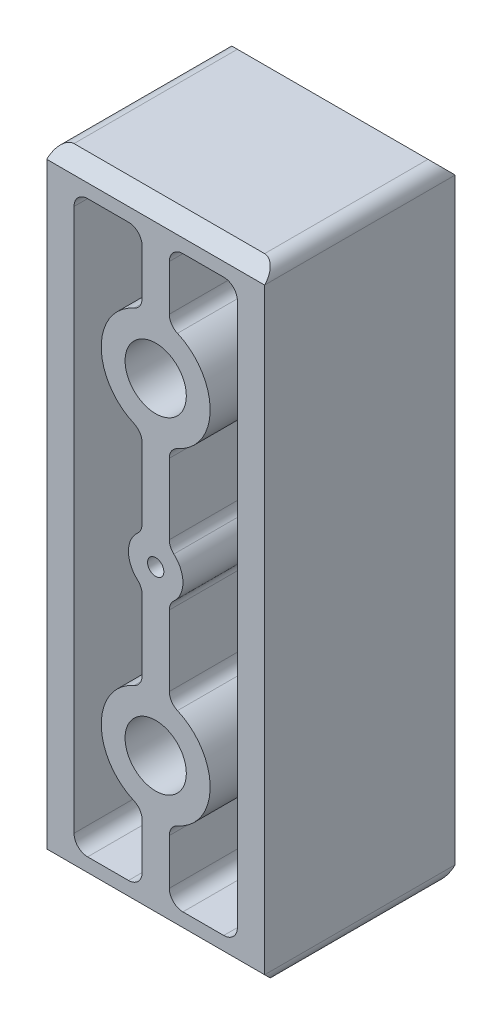
from build123d import *

# Parameters (mm, degrees)
SKETCH1_W                  = 50.8
SKETCH1_H                  = 145.6436
SKETCH1_R                  = 7.14375
BOSS_EXTRUDE1_DEPTH        = 22.225
CUT_EXTRUDE2_DEPTH         = 45.45
FILLET1_R                  = 3.175
CUT_EXTRUDE4_DEPTH         = 51.8
MIRROR3_COPY_1_DEPTH       = 45.45
MIRROR3_COPY_2_DEPTH       = 45.45
MIRROR3_COPY_3_DEPTH       = 51.8
F_10_24_TAPPED_HOLE1_D     = 3.7973
F_10_24_TAPPED_HOLE1_DEPTH = 14.986
F_10_24_TAPPED_HOLE1_TIP   = 1.140824014
FILLET2_R                  = 3.175


with BuildPart() as part:
    # Sketch1 → Boss-Extrude1 (new body, symmetric)
    with BuildSketch(Plane.XY):
        Rectangle(SKETCH1_W, SKETCH1_H)
        with Locations((0, 38.1)):
            Circle(SKETCH1_R, mode=Mode.SUBTRACT)
        with Locations((0, -38.1)):
            Circle(SKETCH1_R, mode=Mode.SUBTRACT)
    extrude(amount=BOSS_EXTRUDE1_DEPTH, both=True)

    # Sketch3 → Cut-Extrude2 (cut, through all)
    with BuildSketch(Plane.XY.offset(22.225)):
        with BuildLine():
            Line((19.05, 66.4718), (19.05, 0))
            Line((19.05, 0), (6.35, 0))
            ThreePointArc((6.35, 0), (5.499261314, 3.175), (3.175, 5.499261314))
            Line((3.175, 5.499261314), (3.175, 25.803277876))
            ThreePointArc((3.175, 25.803277876), (12.7, 38.1), (3.175, 50.396722124))
            Line((3.175, 50.396722124), (3.175, 66.4718))
            Line((3.175, 66.4718), (19.05, 66.4718))
        make_face()
    cut_extrude2 = extrude(amount=-CUT_EXTRUDE2_DEPTH, mode=Mode.SUBTRACT)

    # Mirror4: Cut-Extrude2 across plane
    add(cut_extrude2.mirror(Plane(origin=(0, 0, 0), x_dir=(0, 0, 1), z_dir=(1, 0, 0))), mode=Mode.SUBTRACT)

    # Mirror1: Cut-Extrude2 across plane
    add(cut_extrude2.mirror(Plane.ZX), mode=Mode.SUBTRACT)

    # Fillet1
    fillet1_edges = [part.edges().sort_by_distance(p)[0] for p in [
        (3.175, 50.396722124, 0),
        (19.05, 66.4718, 0),
        (-19.05, 66.4718, 0),
        (-3.175, 50.396722124, 0),
        (-25.4, 72.8218, 0),
        (19.05, -66.4718, 0),
        (25.4, 72.8218, 0),
        (25.4, -72.8218, 0),
        (-25.4, -72.8218, 0),
    ]]
    fillet(fillet1_edges, radius=FILLET1_R)

    # Sketch5 → Cut-Extrude4 (cut, through all)
    with BuildSketch(Plane(origin=(25.4, 0, 0), x_dir=(0, 0, -1), z_dir=(1, 0, 0))):
        Polygon((19.05, 72.8218), (22.225, 69.6468), (22.225, 72.8218), align=None)
    cut_extrude4 = extrude(amount=-CUT_EXTRUDE4_DEPTH, mode=Mode.SUBTRACT)

    # Mirror2: Cut-Extrude4 across plane
    add(cut_extrude4.mirror(Plane.XY), mode=Mode.SUBTRACT)

    # Mirror3: Cut-Extrude4 across plane
    add(cut_extrude4.mirror(Plane.ZX), mode=Mode.SUBTRACT)

    # Mirror3 copy 1 sketch → Mirror3 copy 1 (cut, through all)
    with BuildSketch(Plane(origin=(0, 0, 22.225), x_dir=(-1, 0, 0), z_dir=(0, 0, 1))):
        with BuildLine():
            Line((19.05, 66.4718), (19.05, 0))
            Line((19.05, 0), (6.35, 0))
            ThreePointArc((6.35, 0), (5.499261314, 3.175), (3.175, 5.499261314))
            Line((3.175, 5.499261314), (3.175, 25.803277876))
            ThreePointArc((3.175, 25.803277876), (12.7, 38.1), (3.175, 50.396722124))
            Line((3.175, 50.396722124), (3.175, 66.4718))
            Line((3.175, 66.4718), (19.05, 66.4718))
        make_face()
    extrude(amount=-MIRROR3_COPY_1_DEPTH, mode=Mode.SUBTRACT)

    # Mirror3 copy 2 sketch → Mirror3 copy 2 (cut, through all)
    with BuildSketch(Plane.XY.offset(22.225)):
        with BuildLine():
            Line((19.05, -66.4718), (19.05, 0))
            Line((19.05, 0), (6.35, 0))
            ThreePointArc((6.35, 0), (5.499261314, -3.175), (3.175, -5.499261314))
            Line((3.175, -5.499261314), (3.175, -25.803277876))
            ThreePointArc((3.175, -25.803277876), (12.7, -38.1), (3.175, -50.396722124))
            Line((3.175, -50.396722124), (3.175, -66.4718))
            Line((3.175, -66.4718), (19.05, -66.4718))
        make_face()
    extrude(amount=-MIRROR3_COPY_2_DEPTH, mode=Mode.SUBTRACT)

    # Mirror3 copy 3 sketch → Mirror3 copy 3 (cut, through all)
    with BuildSketch(Plane(origin=(25.4, 0, 0), x_dir=(0, 0, 1), z_dir=(1, 0, 0))):
        Polygon((19.05, 72.8218), (22.225, 69.6468), (22.225, 72.8218), align=None)
    extrude(amount=-MIRROR3_COPY_3_DEPTH, mode=Mode.SUBTRACT)

    # #10-24 Tapped Hole1
    with Locations(Plane.XY.offset(22.225)):
        with Locations((0, 0)):
            Hole(F_10_24_TAPPED_HOLE1_D / 2, depth=F_10_24_TAPPED_HOLE1_DEPTH)
            with Locations((0, 0, -(F_10_24_TAPPED_HOLE1_DEPTH + F_10_24_TAPPED_HOLE1_TIP / 2))):  # 118° drill point
                Cone(0, F_10_24_TAPPED_HOLE1_D / 2, F_10_24_TAPPED_HOLE1_TIP, mode=Mode.SUBTRACT)

    # Fillet2
    fillet2_edges = [part.edges().sort_by_distance(p)[0] for p in [
        (-3.175, -5.499261314, 0),
        (-3.175, -25.803277876, 0),
        (-3.175, -50.396722124, 0),
        (-3.175, -66.4718, 0),
        (-19.05, -66.4718, 0),
        (19.05, -66.4718, 0),
        (3.175, 5.499261314, 0),
        (3.175, 25.803277876, 0),
        (3.175, 66.4718, 0),
        (-3.175, 66.4718, 0),
        (-3.175, 25.803277876, 0),
        (-3.175, 5.499261314, 0),
        (3.175, -66.4718, 0),
        (3.175, -50.396722124, 0),
        (3.175, -25.803277876, 0),
        (3.175, -5.499261314, 0),
    ]]
    fillet(fillet2_edges, radius=FILLET2_R)


solid = part.part
